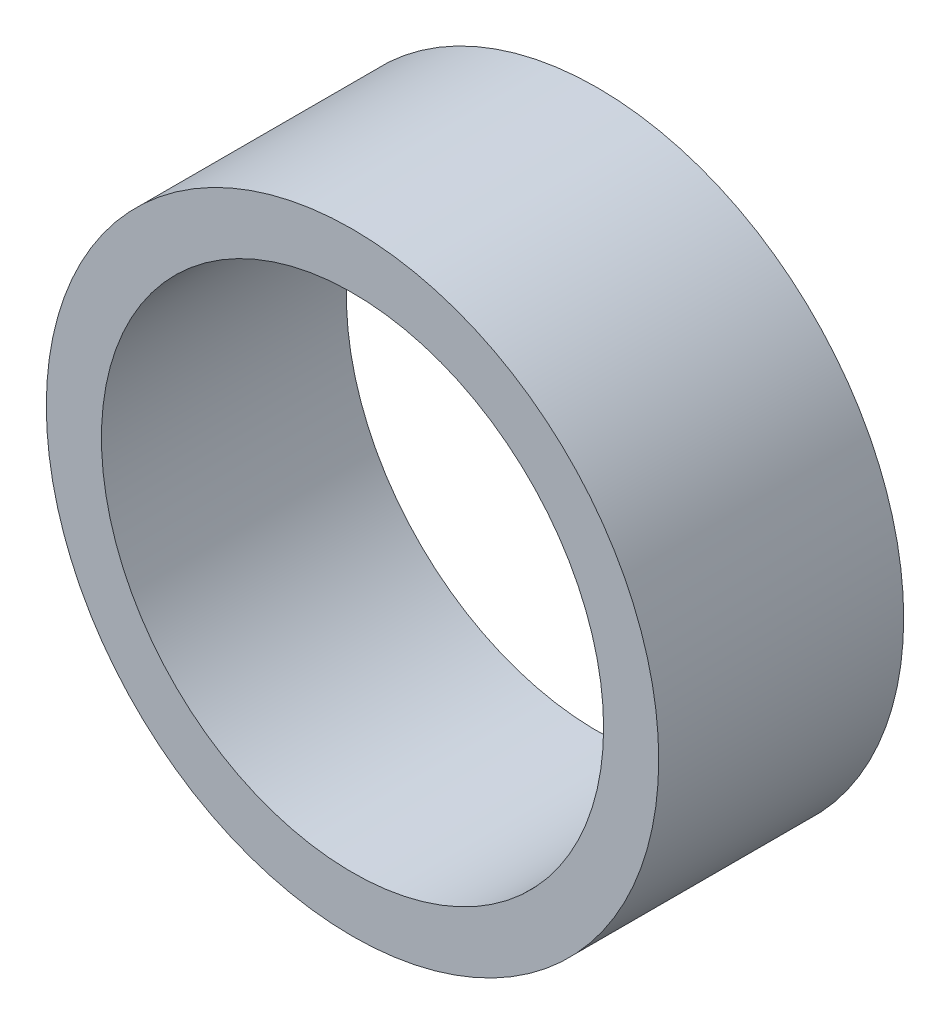
from build123d import *

# Parameters (mm, degrees)
SKETCH_1_R      = 25
SKETCH_1_R_2    = 20.5
EXTRUDE_1_DEPTH = 20


with BuildPart() as part:
    # 草图1 → 凸台-拉伸1 (new body)
    with BuildSketch(Plane.XY):
        with Locations((-86.947641376, 24.600343471)):
            Circle(SKETCH_1_R)
        with Locations((-86.947641376, 24.600343471)):
            Circle(SKETCH_1_R_2, mode=Mode.SUBTRACT)
    extrude(amount=EXTRUDE_1_DEPTH)


solid = part.part
